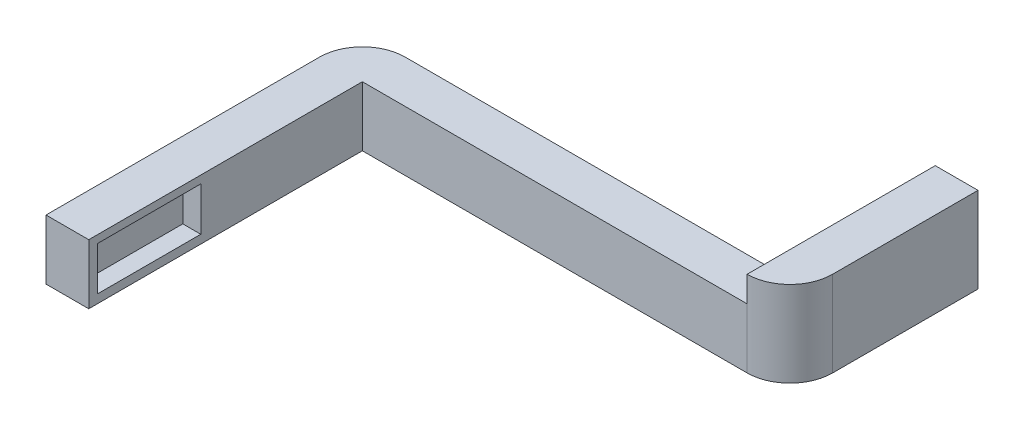
from build123d import *

# Parameters (mm, degrees)
SKETCH1_W           = 45
SKETCH1_H           = 7
BOSS_EXTRUDE1_DEPTH = 5
SKETCH2_W           = 37
SKETCH2_H           = 7
BOSS_EXTRUDE2_DEPTH = 5
FILLET1_R           = 5
SKETCH3_W           = 22
SKETCH3_H           = 10
BOSS_EXTRUDE3_DEPTH = 5
FILLET2_R           = 5
SKETCH4_W           = 12.1
SKETCH4_H           = 5.1
CUT_EXTRUDE1_DEPTH  = 2.1


with BuildPart() as part:
    # Sketch1 → Boss-Extrude1 (new body)
    with BuildSketch(Plane.XY):
        Rectangle(SKETCH1_W, SKETCH1_H)
    extrude(amount=BOSS_EXTRUDE1_DEPTH)

    # Sketch2 → Boss-Extrude2 (add)
    with BuildSketch(Plane.ZY.offset(22.5)):
        with Locations((-13.5, 0)):
            Rectangle(SKETCH2_W, SKETCH2_H)
    extrude(amount=BOSS_EXTRUDE2_DEPTH)

    # Fillet1
    fillet1_edges = [part.edges().sort_by_distance(p)[0] for p in [
        (-27.5, 0, 5),
    ]]
    fillet(fillet1_edges, radius=FILLET1_R)

    # Sketch3 → Boss-Extrude3 (add)
    with BuildSketch(Plane(origin=(22.5, 0, 0), x_dir=(0, 0, -1), z_dir=(1, 0, 0))):
        with Locations((-11, 1.5)):
            Rectangle(SKETCH3_W, SKETCH3_H)
    extrude(amount=BOSS_EXTRUDE3_DEPTH)

    # Fillet2
    fillet2_edges = [part.edges().sort_by_distance(p)[0] for p in [
        (27.5, 1.5, 0),
    ]]
    fillet(fillet2_edges, radius=FILLET2_R)

    # Sketch4 → Cut-Extrude1 (cut)
    with BuildSketch(Plane(origin=(-22.5, 0, 0), x_dir=(0, 0, -1), z_dir=(1, 0, 0))):
        with Locations((24.95, 0.05)):
            Rectangle(SKETCH4_W, SKETCH4_H)
    extrude(amount=-CUT_EXTRUDE1_DEPTH, mode=Mode.SUBTRACT)


with BuildPart() as body_2:
    # Mirror1: mirrored copy
    add(part.part.mirror(Plane(origin=(-27.5, 3.5, -32), x_dir=(1, 0, 0), z_dir=(0, 0, 1))))


solid = body_2.part
